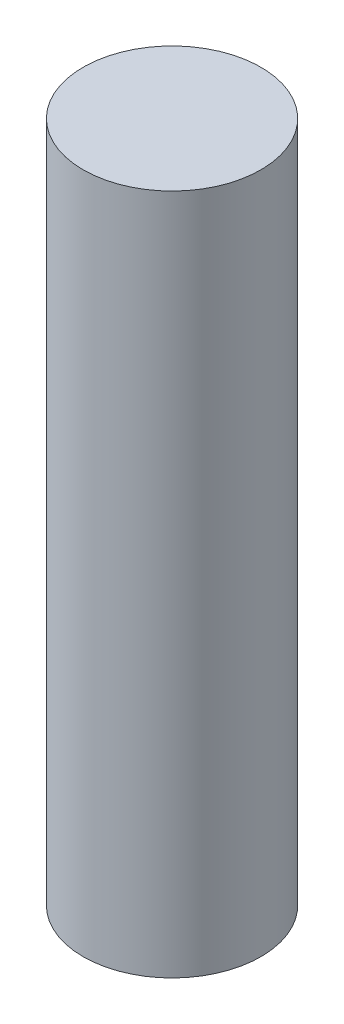
from build123d import *

# Parameters (mm, degrees)
SKETCH2_R           = 3.9751
BOSS_EXTRUDE1_DEPTH = 30.48


with BuildPart() as part:
    # Sketch2 → Boss-Extrude1 (new body)
    with BuildSketch(Plane(origin=(0, 0, 0), x_dir=(1, 0, 0), z_dir=(0, 1, 0))):
        Circle(SKETCH2_R)
    extrude(amount=BOSS_EXTRUDE1_DEPTH)


solid = part.part
